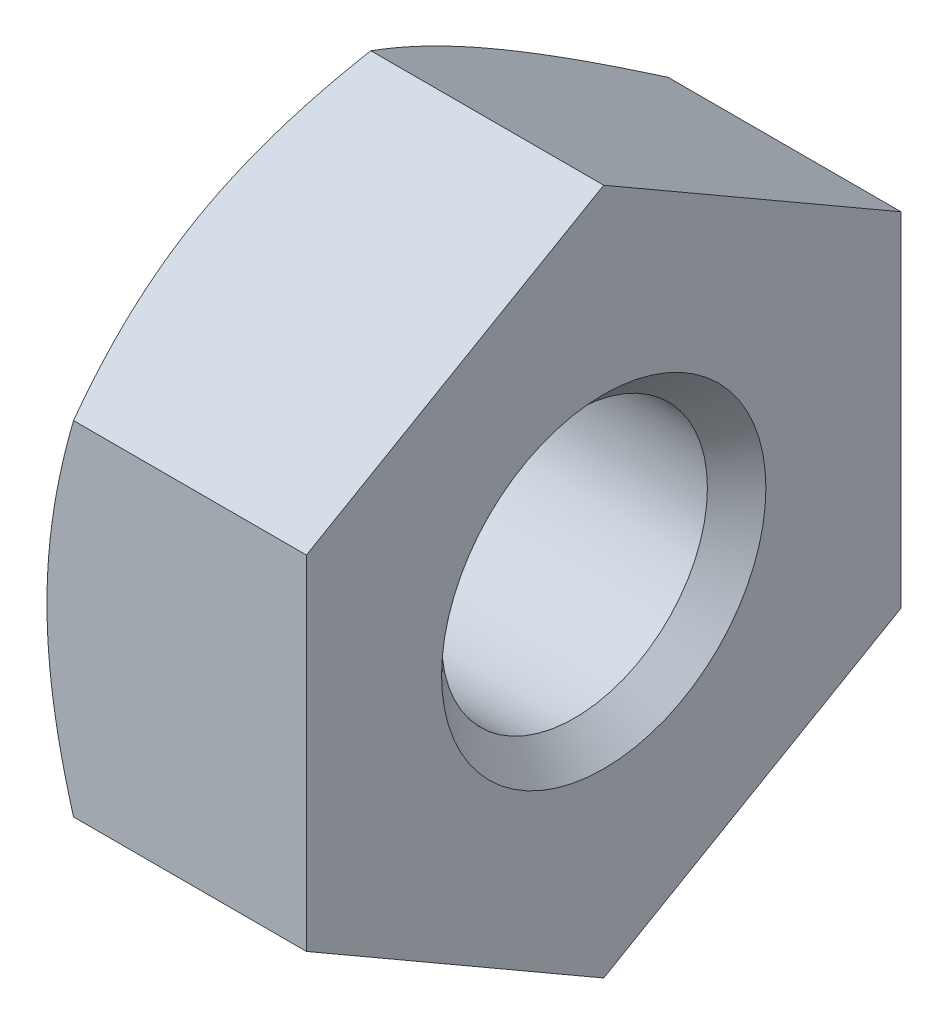
from build123d import *

# Parameters (mm, degrees)
CUT_EXTRUDE1_DEPTH      = 1.2
CUT_EXTRUDE1_DEPTH_BACK = 1.2
SKETCH3_W               = 11
SKETCH3_H               = 11


with BuildPart() as part:
    # Sketch1 → Revolve1 (revolve)
    with BuildSketch(Plane.XY):
        Polygon((-1.2, 0), (-1.2, 2.75), (-0.940192379, 3.2), (1.2, 3.2), (1.2, 0), align=None)
    revolve(axis=Axis((1.2, 0, 0), (-1, 0, 0)))

    # Sketch2 → Cut-Revolve1 (revolve, cut)
    with BuildSketch(Plane.XY):
        Polygon((-1.2, 0), (-1.2, 1.5), (-0.9295, 1.2295), (0.9295, 1.2295), (1.2, 1.5), (1.2, 0), align=None)
    revolve(axis=Axis((1.2, 0, 0), (-1, 0, 0)), mode=Mode.SUBTRACT)

    # Sketch3 → Cut-Extrude1 (cut, two sides: drawn at the far end of the back side and taken through both)
    with BuildSketch(Plane(origin=(0, 0, 0), x_dir=(0, 0, -1), z_dir=(1, 0, 0)).offset(-CUT_EXTRUDE1_DEPTH_BACK)):
        Rectangle(SKETCH3_W, SKETCH3_H)
        Polygon((-2.75, -1.58771324), (0, -3.175426481), (2.75, -1.58771324), (2.75, 1.58771324), (0, 3.175426481), (-2.75, 1.58771324), align=None, mode=Mode.SUBTRACT)
    extrude(amount=CUT_EXTRUDE1_DEPTH + CUT_EXTRUDE1_DEPTH_BACK, mode=Mode.SUBTRACT)


solid = part.part
